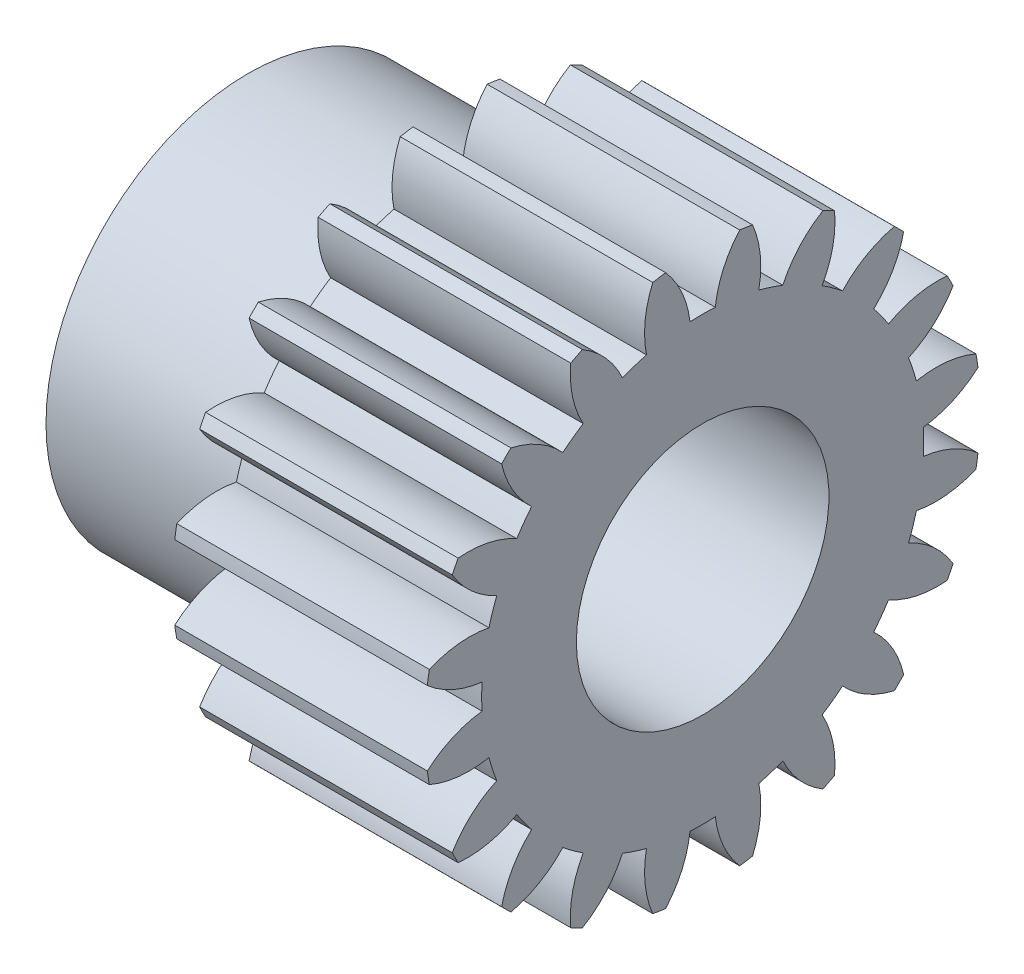
from build123d import *

# Parameters (mm, degrees)
BASPROSKE_W      = 10
BASPROSKE_H      = 11
TOOTHCUT_DEPTH   = 19.493242009
TEETHCUTS_COUNT  = 20
TEETHCUTS_ANGLE  = 342
HUBNEAONESKE_R   = 8
HUBNEARONE_DEPTH = 8.0000508
BORSKE_R         = 5
BORE_DEPTH       = 18.0000508


with BuildPart() as part:
    # BasProSke → Base-Revolve (revolve)
    with BuildSketch(Plane(origin=(0, 0, 0), x_dir=(1, 0, 0), z_dir=(0, 1, 0)), mode=Mode.PRIVATE) as base_revolve_sk:
        with Locations((5, 5.5)):
            Rectangle(BASPROSKE_W, BASPROSKE_H)
    revolve(base_revolve_sk.sketch.rotate(Axis((-10, 0, 0), (1, 0, 0)), 180), axis=Axis((-10, 0, 0), (1, 0, 0)))

    # TooCutSke → ToothCut (cut, through all)
    with BuildSketch(Plane(origin=(0, 0, 0), x_dir=(0, 0, -1), z_dir=(1, 0, 0))):
        with BuildLine():
            ThreePointArc((0.499924007, 8.734705318), (0, 8.749), (-0.499924007, 8.734705318))
            ThreePointArc((-0.499924007, 8.734705318), (-0.824302243, 9.905497836), (-1.485192705, 10.924909509))
            ThreePointArc((-1.485192705, 10.924909509), (0, 11.0254), (1.485192705, 10.924909509))
            ThreePointArc((1.485192705, 10.924909509), (0.824302243, 9.905497836), (0.499924007, 8.734705318))
        make_face()
    toothcut = extrude(amount=TOOTHCUT_DEPTH, mode=Mode.SUBTRACT)

    # TeethCuts: ToothCut ×20 about axis
    teethcuts_axis = Axis((-10, 0, 0), (1, 0, 0))
    for i in range(1, TEETHCUTS_COUNT):
        add(toothcut.rotate(teethcuts_axis, i * TEETHCUTS_ANGLE / (TEETHCUTS_COUNT - 1)), mode=Mode.SUBTRACT)

    # HubNeaOneSke → HubNearOne (add)
    with BuildSketch(Plane.ZY):
        with Locations(Location((0, 0, 0), (0, 0, 180))):
            Circle(HUBNEAONESKE_R)
    extrude(amount=HUBNEARONE_DEPTH)

    # BorSke → Bore (cut, symmetric)
    with BuildSketch(Plane(origin=(0, 0, 0), x_dir=(0, 0, -1), z_dir=(1, 0, 0))):
        with Locations(Location((0, 0, 0), (0, 0, 180))):
            Circle(BORSKE_R)
    extrude(amount=BORE_DEPTH, both=True, mode=Mode.SUBTRACT)


solid = part.part
